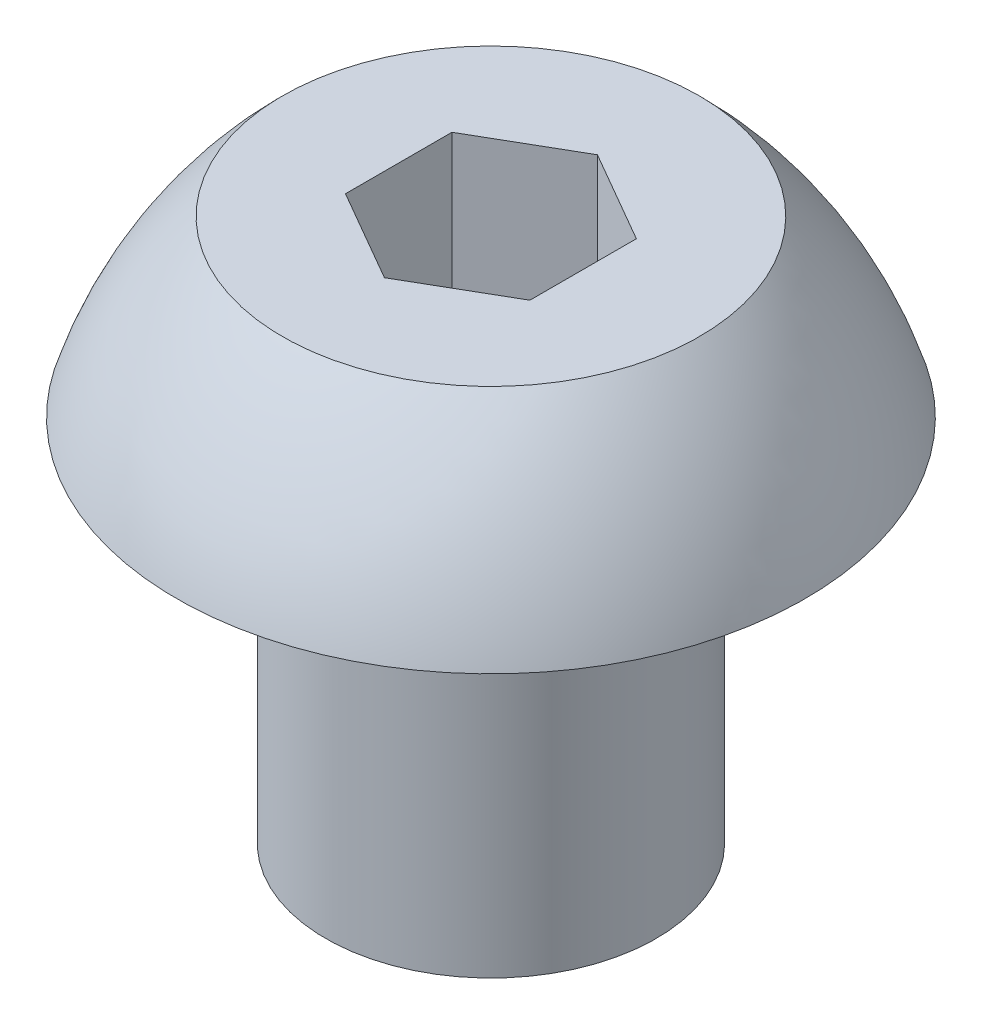
from build123d import *

# Parameters (mm, degrees)
CUT_EXTRUDE1_DEPTH = 1.27


with BuildPart() as part:
    # Sketch1 → Revolve1 (revolve)
    with BuildSketch(Plane.XY):
        with BuildLine():
            Line((-1.4224, 0), (-2.7051, 0))
            ThreePointArc((-2.7051, 0), (-2.343607569, 0.806201731), (-1.79477003, 1.4986))
            Line((-1.79477003, 1.4986), (0, 1.4986))
            Line((0, 1.4986), (0, -3.175))
            Line((0, -3.175), (-1.4224, -3.175))
            Line((-1.4224, -3.175), (-1.4224, 0))
        make_face()
    revolve(axis=Axis((0, -3.175, 0), (0, 1, 0)))

    # Sketch2 → Cut-Extrude1 (cut)
    with BuildSketch(Plane(origin=(0, 1.4986, 0), x_dir=(1, 0, 0), z_dir=(0, 1, 0))):
        Polygon((-0.79375, 0.458271776), (-0.79375, -0.458271776), (0, -0.916543552), (0.79375, -0.458271776), (0.79375, 0.458271776), (0, 0.916543552), align=None)
    extrude(amount=-CUT_EXTRUDE1_DEPTH, mode=Mode.SUBTRACT)


solid = part.part
